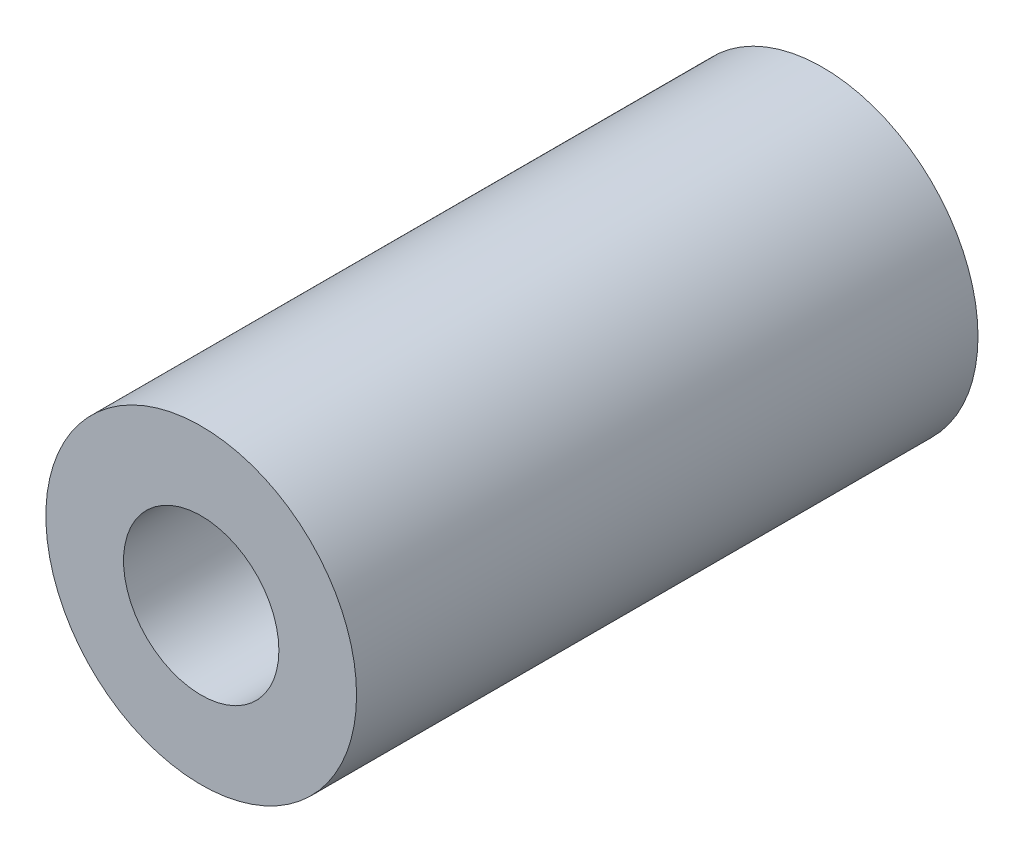
from build123d import *

# Parameters (mm, degrees)
SKETCH1_R           = 3
SKETCH1_R_2         = 1.5
BOSS_EXTRUDE1_DEPTH = 12


with BuildPart() as part:
    # Sketch1 → Boss-Extrude1 (new body)
    with BuildSketch(Plane.XY):
        Circle(SKETCH1_R)
        Circle(SKETCH1_R_2, mode=Mode.SUBTRACT)
    extrude(amount=BOSS_EXTRUDE1_DEPTH)


solid = part.part
